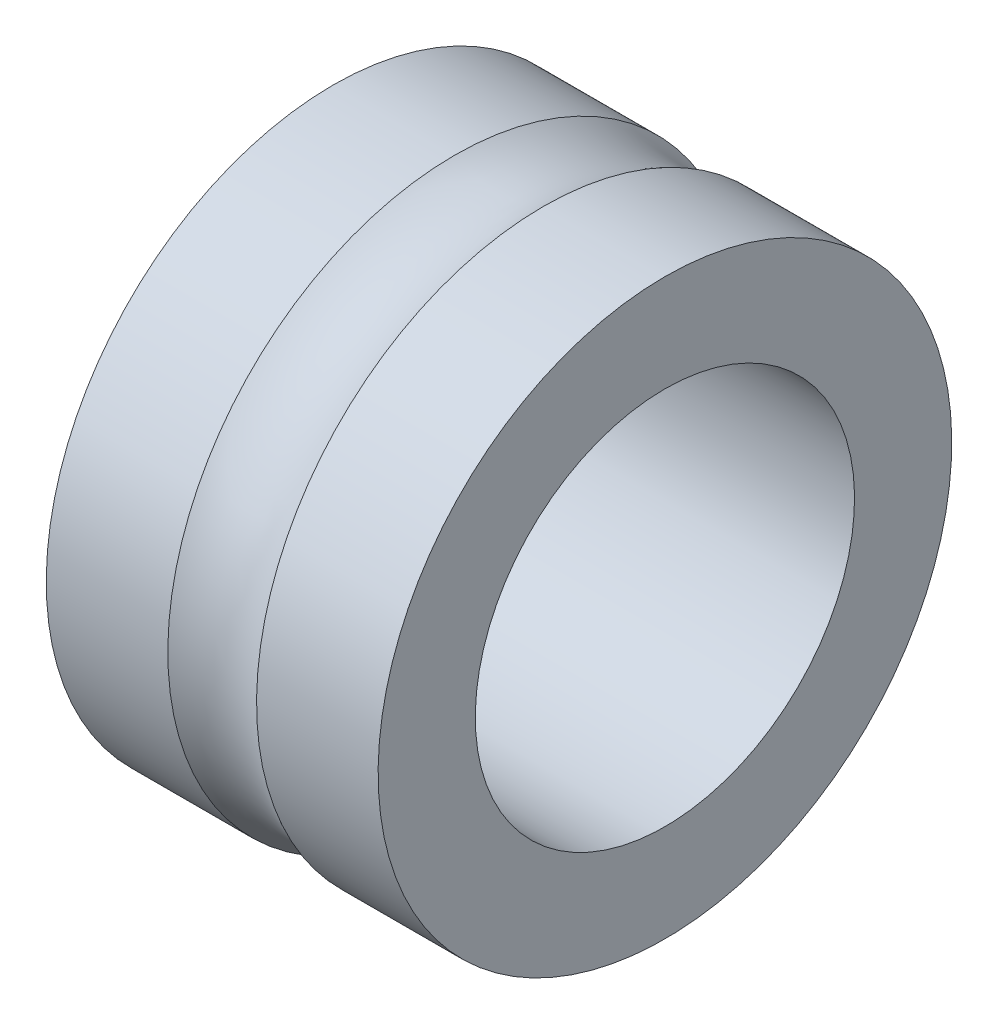
from build123d import *


with BuildPart() as part:
    # Sketch2 → Revolve1 (revolve)
    with BuildSketch(Plane.XY):
        with BuildLine():
            ThreePointArc((0.935809943, 6.05), (0, 5.8155), (-0.935809943, 6.05))
            Line((-0.935809943, 6.05), (-3.5, 6.05))
            Line((-3.5, 6.05), (-3.5, 4))
            Line((-3.5, 4), (3.5, 4))
            Line((3.5, 4), (3.5, 6.05))
            Line((3.5, 6.05), (0.935809943, 6.05))
        make_face()
    revolve(axis=Axis((23.660185957, 0, 0), (-1, 0, 0)))


solid = part.part
